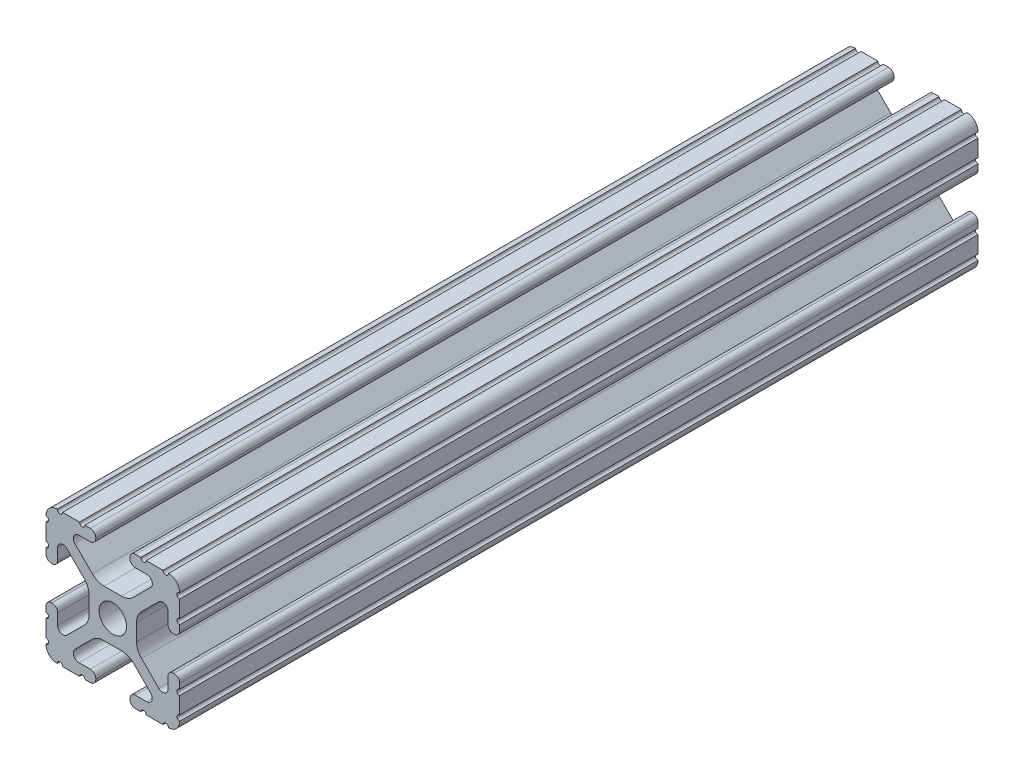
from build123d import *

# Parameters (mm, degrees)
SKETCH1_R           = 2.6035
BOSS_EXTRUDE1_DEPTH = 914.4
SKETCH2_W           = 591.784504761
SKETCH2_H           = 34.760821459
SKETCH2_W_2         = 1099.97900941
SKETCH2_H_2         = 36.169365112
CUT_EXTRUDE1_DEPTH  = 27.432


with BuildPart() as part:
    # Sketch1 → Boss-Extrude1 (new body, symmetric)
    with BuildSketch(Plane.XY):
        with BuildLine():
            Line((-7.179650497, -8.645192506), (-3.952270251, -5.423690499))
            ThreePointArc((-3.952270251, -5.423690499), (-2.922936451, -4.736929036), (-1.709253557, -4.4958))
            Line((-1.709253557, -4.4958), (1.709253557, -4.4958))
            ThreePointArc((1.709253557, -4.4958), (2.922936451, -4.736929036), (3.952270251, -5.423690499))
            Line((3.952270251, -5.423690499), (7.179650497, -8.645192506))
            ThreePointArc((7.179650497, -8.645192506), (7.41473083, -9.822813117), (6.416408329, -10.4902))
            Line((6.416408329, -10.4902), (4.287512407, -10.4902))
            ThreePointArc((4.287512407, -10.4902), (3.54574862, -10.79744862), (3.2385, -11.539212407))
            Line((3.2385, -11.539212407), (3.2385, -11.650987593))
            ThreePointArc((3.2385, -11.650987593), (3.54574862, -12.39275138), (4.287512407, -12.7))
            Line((4.287512407, -12.7), (5.317126718, -12.7))
            ThreePointArc((5.317126718, -12.7), (5.825126718, -12.192), (6.333126718, -12.7))
            Line((6.333126718, -12.7), (9.550443118, -12.7))
            ThreePointArc((9.550443118, -12.7), (10.058366869, -12.192000006), (10.566443095, -12.699847501))
            ThreePointArc((10.566443095, -12.699847501), (12.082537762, -12.08250727), (12.699846982, -10.566399977))
            ThreePointArc((12.699846982, -10.566399977), (12.192000006, -10.058323491), (12.7, -9.5504))
            Line((12.7, -9.5504), (12.7, -6.3330836))
            ThreePointArc((12.7, -6.3330836), (12.192, -5.8250836), (12.7, -5.3170836))
            Line((12.7, -5.3170836), (12.7, -4.287469289))
            ThreePointArc((12.7, -4.287469289), (12.39275138, -3.545705502), (11.650987593, -3.238456882))
            Line((11.650987593, -3.238456882), (11.539212407, -3.238456882))
            ThreePointArc((11.539212407, -3.238456882), (10.79744862, -3.545705502), (10.4902, -4.287469289))
            Line((10.4902, -4.287469289), (10.4902, -6.402089023))
            ThreePointArc((10.4902, -6.402089023), (9.856505071, -7.351067942), (8.737131347, -7.129408934))
            Line((8.737131347, -7.129408934), (5.441005833, -3.840816462))
            ThreePointArc((5.441005833, -3.840816462), (4.750877967, -2.809883091), (4.5085, -1.593185507))
            Line((4.5085, -1.593185507), (4.5085, 1.593185507))
            ThreePointArc((4.5085, 1.593185507), (4.750877967, 2.809883091), (5.441005833, 3.840816462))
            Line((5.441005833, 3.840816462), (8.737131347, 7.129408934))
            ThreePointArc((8.737131347, 7.129408934), (9.856505071, 7.351067942), (10.4902, 6.402089023))
            Line((10.4902, 6.402089023), (10.4902, 4.287469289))
            ThreePointArc((10.4902, 4.287469289), (10.79744862, 3.545705502), (11.539212407, 3.238456882))
            Line((11.539212407, 3.238456882), (11.650987593, 3.238456882))
            ThreePointArc((11.650987593, 3.238456882), (12.39275138, 3.545705502), (12.7, 4.287469289))
            Line((12.7, 4.287469289), (12.7, 5.3170836))
            ThreePointArc((12.7, 5.3170836), (12.192, 5.8250836), (12.7, 6.3330836))
            Line((12.7, 6.3330836), (12.7, 9.5504))
            ThreePointArc((12.7, 9.5504), (12.192000006, 10.058323491), (12.699846982, 10.566399977))
            ThreePointArc((12.699846982, 10.566399977), (12.082537762, 12.08250727), (10.566443095, 12.699847501))
            ThreePointArc((10.566443095, 12.699847501), (10.058366869, 12.192000006), (9.550443118, 12.7))
            Line((9.550443118, 12.7), (6.333126718, 12.7))
            ThreePointArc((6.333126718, 12.7), (5.825126718, 12.192), (5.317126718, 12.7))
            Line((5.317126718, 12.7), (4.287512407, 12.7))
            ThreePointArc((4.287512407, 12.7), (3.54574862, 12.39275138), (3.2385, 11.650987593))
            Line((3.2385, 11.650987593), (3.2385, 11.539212407))
            ThreePointArc((3.2385, 11.539212407), (3.54574862, 10.79744862), (4.287512407, 10.4902))
            Line((4.287512407, 10.4902), (6.476788598, 10.4902))
            ThreePointArc((6.476788598, 10.4902), (7.432222385, 9.85140422), (7.207036008, 8.724370562))
            Line((7.207036008, 8.724370562), (3.898272566, 5.423169045))
            ThreePointArc((3.898272566, 5.423169045), (2.869120213, 4.736787962), (1.655778399, 4.4958))
            Line((1.655778399, 4.4958), (-1.655778399, 4.4958))
            ThreePointArc((-1.655778399, 4.4958), (-2.869120213, 4.736787962), (-3.898272566, 5.423169045))
            Line((-3.898272566, 5.423169045), (-7.207036008, 8.724370562))
            ThreePointArc((-7.207036008, 8.724370562), (-7.432222385, 9.85140422), (-6.476788598, 10.4902))
            Line((-6.476788598, 10.4902), (-4.287512407, 10.4902))
            ThreePointArc((-4.287512407, 10.4902), (-3.54574862, 10.79744862), (-3.2385, 11.539212407))
            Line((-3.2385, 11.539212407), (-3.2385, 11.650987593))
            ThreePointArc((-3.2385, 11.650987593), (-3.54574862, 12.39275138), (-4.287512407, 12.7))
            Line((-4.287512407, 12.7), (-5.317126718, 12.7))
            ThreePointArc((-5.317126718, 12.7), (-5.825126718, 12.192), (-6.333126718, 12.7))
            Line((-6.333126718, 12.7), (-9.550443118, 12.7))
            ThreePointArc((-9.550443118, 12.7), (-10.058366869, 12.192000006), (-10.566443095, 12.699847501))
            ThreePointArc((-10.566443095, 12.699847501), (-12.082537762, 12.08250727), (-12.699846982, 10.566399977))
            ThreePointArc((-12.699846982, 10.566399977), (-12.192000006, 10.058323491), (-12.7, 9.5504))
            Line((-12.7, 9.5504), (-12.7, 6.3330836))
            ThreePointArc((-12.7, 6.3330836), (-12.192, 5.8250836), (-12.7, 5.3170836))
            Line((-12.7, 5.3170836), (-12.7, 4.287469289))
            ThreePointArc((-12.7, 4.287469289), (-12.39275138, 3.545705502), (-11.650987593, 3.238456882))
            Line((-11.650987593, 3.238456882), (-11.539212407, 3.238456882))
            ThreePointArc((-11.539212407, 3.238456882), (-10.79744862, 3.545705502), (-10.4902, 4.287469289))
            Line((-10.4902, 4.287469289), (-10.4902, 6.402089023))
            ThreePointArc((-10.4902, 6.402089023), (-9.856505071, 7.351067942), (-8.737131347, 7.129408934))
            Line((-8.737131347, 7.129408934), (-5.441005833, 3.840816462))
            ThreePointArc((-5.441005833, 3.840816462), (-4.750877967, 2.809883091), (-4.5085, 1.593185507))
            Line((-4.5085, 1.593185507), (-4.5085, -1.593185507))
            ThreePointArc((-4.5085, -1.593185507), (-4.750877967, -2.809883091), (-5.441005833, -3.840816462))
            Line((-5.441005833, -3.840816462), (-8.737131347, -7.129408934))
            ThreePointArc((-8.737131347, -7.129408934), (-9.856505071, -7.351067942), (-10.4902, -6.402089023))
            Line((-10.4902, -6.402089023), (-10.4902, -4.287469289))
            ThreePointArc((-10.4902, -4.287469289), (-10.79744862, -3.545705502), (-11.539212407, -3.238456882))
            Line((-11.539212407, -3.238456882), (-11.650987593, -3.238456882))
            ThreePointArc((-11.650987593, -3.238456882), (-12.39275138, -3.545705502), (-12.7, -4.287469289))
            Line((-12.7, -4.287469289), (-12.7, -5.3170836))
            ThreePointArc((-12.7, -5.3170836), (-12.192, -5.8250836), (-12.7, -6.3330836))
            Line((-12.7, -6.3330836), (-12.7, -9.5504))
            ThreePointArc((-12.7, -9.5504), (-12.192000006, -10.058323491), (-12.699846982, -10.566399977))
            ThreePointArc((-12.699846982, -10.566399977), (-12.082537762, -12.08250727), (-10.566443095, -12.699847501))
            ThreePointArc((-10.566443095, -12.699847501), (-10.058366869, -12.192000006), (-9.550443118, -12.7))
            Line((-9.550443118, -12.7), (-6.333126718, -12.7))
            ThreePointArc((-6.333126718, -12.7), (-5.825126718, -12.192), (-5.317126718, -12.7))
            Line((-5.317126718, -12.7), (-4.287512407, -12.7))
            ThreePointArc((-4.287512407, -12.7), (-3.54574862, -12.39275138), (-3.2385, -11.650987593))
            Line((-3.2385, -11.650987593), (-3.2385, -11.539212407))
            ThreePointArc((-3.2385, -11.539212407), (-3.54574862, -10.79744862), (-4.287512407, -10.4902))
            Line((-4.287512407, -10.4902), (-6.416408329, -10.4902))
            ThreePointArc((-6.416408329, -10.4902), (-7.41473083, -9.822813117), (-7.179650497, -8.645192506))
        make_face()
        Circle(SKETCH1_R, mode=Mode.SUBTRACT)
    extrude(amount=BOSS_EXTRUDE1_DEPTH, both=True)

    # Sketch2 → Cut-Extrude1 (cut)
    with BuildSketch(Plane(origin=(12.7, 0, 0), x_dir=(0, 0, -1), z_dir=(1, 0, 0))):
        with Locations((-622.565020226, -0.58573738)):
            Rectangle(SKETCH2_W, SKETCH2_H)
        with Locations((375.067711741, 0.118534447)):
            Rectangle(SKETCH2_W_2, SKETCH2_H_2)
    extrude(amount=-CUT_EXTRUDE1_DEPTH, mode=Mode.SUBTRACT)


solid = part.part
